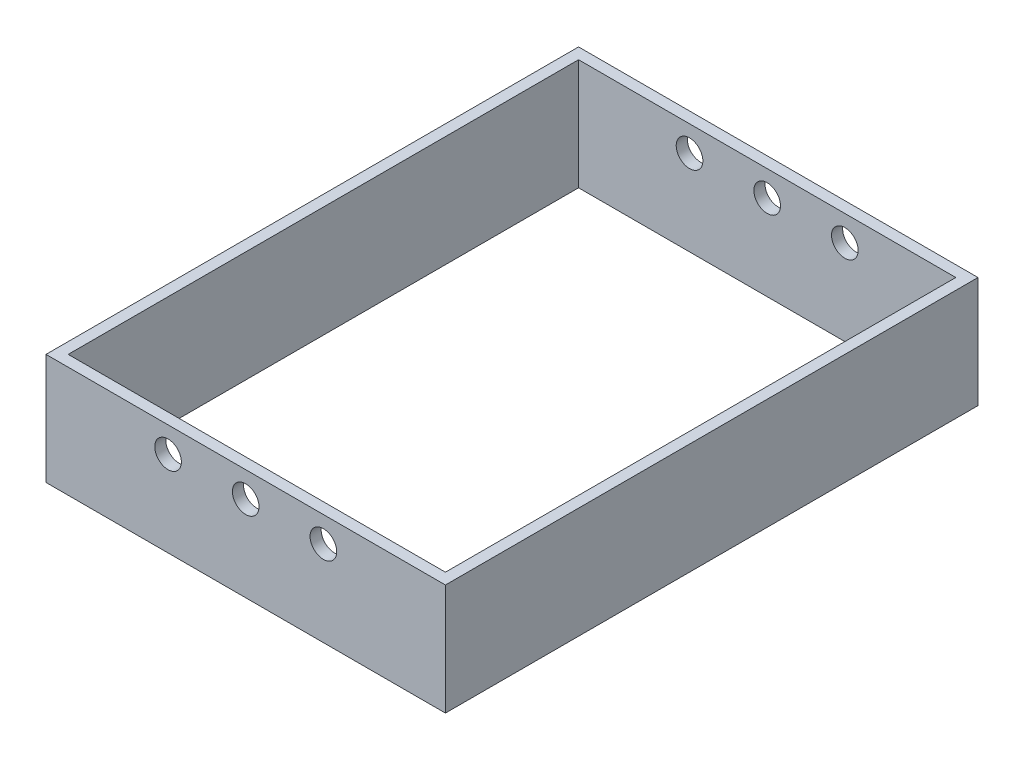
from build123d import *

# Parameters (mm, degrees)
CROQUIS1_W              = 180
CROQUIS1_H              = 240
CROQUIS1_W_2            = 170
CROQUIS1_H_2            = 230
SALIENTE_EXTRUIR1_DEPTH = 50
CROQUIS2_R              = 6
CORTAR_EXTRUIR1_DEPTH   = 241


with BuildPart() as part:
    # Croquis1 → Saliente-Extruir1 (new body)
    with BuildSketch(Plane(origin=(0, 0, 0), x_dir=(1, 0, 0), z_dir=(0, 1, 0))):
        Rectangle(CROQUIS1_W, CROQUIS1_H)
        Rectangle(CROQUIS1_W_2, CROQUIS1_H_2, mode=Mode.SUBTRACT)
    extrude(amount=SALIENTE_EXTRUIR1_DEPTH)

    # Croquis2 → Cortar-Extruir1 (cut, through all)
    with BuildSketch(Plane.XY.offset(120)):
        with Locations((-35, 38.5)):
            Circle(CROQUIS2_R)
        with Locations((0, 38.5)):
            Circle(CROQUIS2_R)
        with Locations((35, 38.5)):
            Circle(CROQUIS2_R)
    extrude(amount=-CORTAR_EXTRUIR1_DEPTH, mode=Mode.SUBTRACT)


solid = part.part
